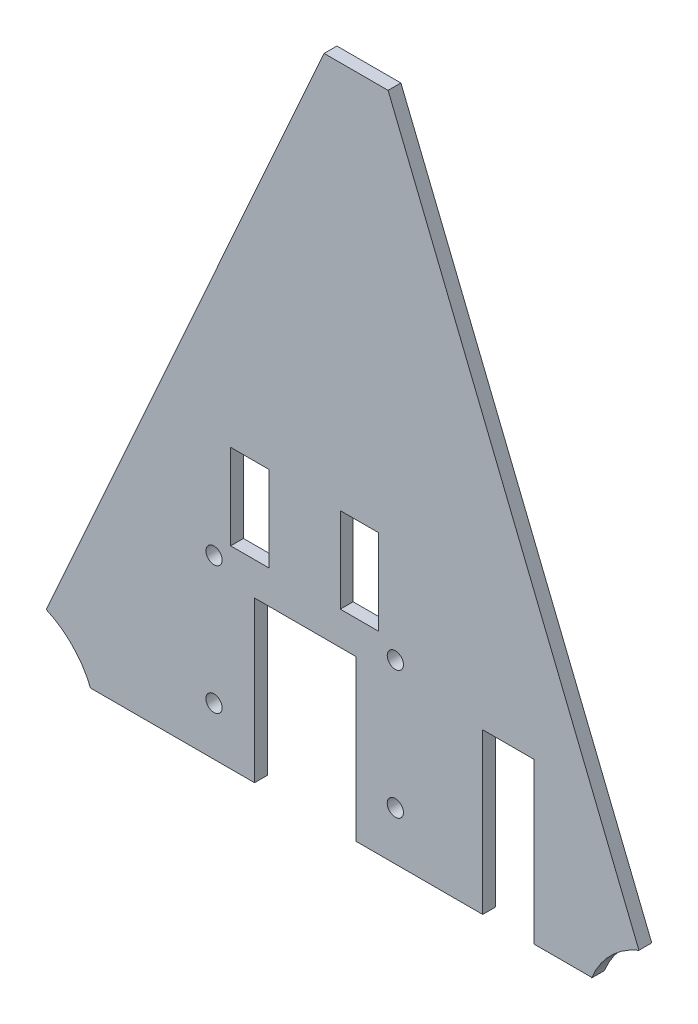
from build123d import *

# Parameters (mm, degrees)
BOSS_EXTRUDE1_DEPTH     = 7.62
SKETCH5_R               = 15.875
CUT_EXTRUDE2_DEPTH      = 50.8
SKETCH6_R               = 15.875
CUT_EXTRUDE3_DEPTH      = 50.8
CUT_EXTRUDE4_DEPTH      = 1
CUT_EXTRUDE4_DEPTH_BACK = 7.62
CUT_EXTRUDE6_REACH      = 9.62
SKETCH9_R               = 4.826
SKETCH10_W              = 30.48
SKETCH10_H              = 114.3
CUT_EXTRUDE12_DEPTH     = 25.4
CUT_EXTRUDE14_REACH     = 9.62
SKETCH14_R              = 50.8
CUT_EXTRUDE15_REACH     = 9.62
SKETCH15_R              = 50.8
CUT_EXTRUDE17_START     = -7.62
SKETCH18_W              = 300.609514784
SKETCH18_H              = 19.05
CUT_EXTRUDE17_DEPTH     = 7.62
CUT_EXTRUDE18_REACH     = 9.62
SKETCH19_R              = 4.826
CUT_EXTRUDE19_REACH     = 9.62
SKETCH20_W              = 22.86
SKETCH20_H              = 50.8
CUT_EXTRUDE20_REACH     = 9.62
SKETCH21_W              = 12.7
SKETCH21_H              = 95.25


with BuildPart() as part:
    # Sketch2 → Boss-Extrude1 (new body)
    with BuildSketch(Plane.XY):
        Polygon((-189.740054039, 245.383385713), (-375.90852523, -170.414614287), (16.77547477, -170.414614287), (-151.640054039, 245.383385713), align=None)
    extrude(amount=BOSS_EXTRUDE1_DEPTH)

    # Sketch5 → Cut-Extrude2 (cut)
    with BuildSketch(Plane(origin=(0, 0, 0), x_dir=(-1, 0, 0), z_dir=(0, 0, -1))):
        with Locations((375.90852523, -170.414614287)):
            Circle(SKETCH5_R)
    extrude(amount=-CUT_EXTRUDE2_DEPTH, mode=Mode.SUBTRACT)

    # Sketch6 → Cut-Extrude3 (cut)
    with BuildSketch(Plane(origin=(0, 0, 0), x_dir=(-1, 0, 0), z_dir=(0, 0, -1))):
        with Locations((-16.77547477, -170.414614287)):
            Circle(SKETCH6_R)
    extrude(amount=-CUT_EXTRUDE3_DEPTH, mode=Mode.SUBTRACT)

    # Sketch8 → Cut-Extrude4 (cut, two sides)
    with BuildSketch(Plane(origin=(0, 0, 0), x_dir=(-1, 0, 0), z_dir=(0, 0, -1))) as cut_extrude4_sk:
        Polygon((218.448947474, -1130.046710402), (218.448947474, -170.414614287), (218.448947474, -56.114614287), (183.523947474, -56.114614287), (183.523947474, -170.414614287), (183.523947474, -1130.046710402), (183.523947474, -3049.310902633), (218.448947474, -3049.310902633), align=None)
    extrude(amount=CUT_EXTRUDE4_DEPTH, mode=Mode.SUBTRACT)
    extrude(cut_extrude4_sk.sketch, amount=-CUT_EXTRUDE4_DEPTH_BACK, mode=Mode.SUBTRACT)

    # Sketch9 → Cut-Extrude6 (cut, up to next)
    with BuildSketch(Plane(origin=(0, 0, 0), x_dir=(-1, 0, 0), z_dir=(0, 0, -1)), mode=Mode.PRIVATE) as cut_extrude6_sk1:
        with Locations((147.328947474, -122.408614287)):
            Circle(SKETCH9_R)
    cut_extrude6_tool1 = extrude(cut_extrude6_sk1.sketch, amount=-CUT_EXTRUDE6_REACH, mode=Mode.PRIVATE) & part.part
    add(cut_extrude6_tool1.solids().sort_by_distance((-147.328947, -122.408614, 0))[0], mode=Mode.SUBTRACT)
    # Sketch9 → Cut-Extrude6 (cut, up to next)
    with BuildSketch(Plane(origin=(0, 0, 0), x_dir=(-1, 0, 0), z_dir=(0, 0, -1)), mode=Mode.PRIVATE) as cut_extrude6_sk2:
        with Locations((255.278947474, -122.408614287)):
            Circle(SKETCH9_R)
    cut_extrude6_tool2 = extrude(cut_extrude6_sk2.sketch, amount=-CUT_EXTRUDE6_REACH, mode=Mode.PRIVATE) & part.part
    add(cut_extrude6_tool2.solids().sort_by_distance((-255.278947, -122.408614, 0))[0], mode=Mode.SUBTRACT)

    # Sketch10 → Cut-Extrude12 (cut)
    with BuildSketch(Plane(origin=(0, 0, 0), x_dir=(-1, 0, 0), z_dir=(0, 0, -1))):
        with Locations((80.066257047, -113.264614287)):
            Rectangle(SKETCH10_W, SKETCH10_H)
    extrude(amount=-CUT_EXTRUDE12_DEPTH, mode=Mode.SUBTRACT)

    # Sketch14 → Cut-Extrude14 (cut, up to next)
    with BuildSketch(Plane(origin=(0, 0, 0), x_dir=(-1, 0, 0), z_dir=(0, 0, -1)), mode=Mode.PRIVATE) as cut_extrude14_sk1:
        with Locations((-16.77547477, -170.414614287)):
            Circle(SKETCH14_R)
    cut_extrude14_tool1 = extrude(cut_extrude14_sk1.sketch, amount=-CUT_EXTRUDE14_REACH, mode=Mode.PRIVATE) & part.part
    add(cut_extrude14_tool1.solids().sort_by_distance((16.775475, -170.414614, 0))[0], mode=Mode.SUBTRACT)

    # Sketch15 → Cut-Extrude15 (cut, up to next)
    with BuildSketch(Plane(origin=(0, 0, 0), x_dir=(-1, 0, 0), z_dir=(0, 0, -1)), mode=Mode.PRIVATE) as cut_extrude15_sk1:
        with Locations((375.90852523, -170.414614287)):
            Circle(SKETCH15_R)
    cut_extrude15_tool1 = extrude(cut_extrude15_sk1.sketch, amount=-CUT_EXTRUDE15_REACH, mode=Mode.PRIVATE) & part.part
    add(cut_extrude15_tool1.solids().sort_by_distance((-375.908525, -170.414614, 0))[0], mode=Mode.SUBTRACT)

    # Sketch18 → Cut-Extrude17 (cut)
    with BuildSketch(Plane(origin=(0, 0, 0), x_dir=(-1, 0, 0), z_dir=(0, 0, -1)).offset(CUT_EXTRUDE17_START)):
        with Locations((180.749872138, -160.889614287)):
            Rectangle(SKETCH18_W, SKETCH18_H)
    extrude(amount=CUT_EXTRUDE17_DEPTH, mode=Mode.SUBTRACT)

    # Sketch19 → Cut-Extrude18 (cut, up to next)
    with BuildSketch(Plane(origin=(0, 0, 0), x_dir=(-1, 0, 0), z_dir=(0, 0, -1)), mode=Mode.PRIVATE) as cut_extrude18_sk1:
        with Locations((255.278947474, -46.208614287)):
            Circle(SKETCH19_R)
    cut_extrude18_tool1 = extrude(cut_extrude18_sk1.sketch, amount=-CUT_EXTRUDE18_REACH, mode=Mode.PRIVATE) & part.part
    add(cut_extrude18_tool1.solids().sort_by_distance((-255.278947, -46.208614, 0))[0], mode=Mode.SUBTRACT)
    # Sketch19 → Cut-Extrude18 (cut, up to next)
    with BuildSketch(Plane(origin=(0, 0, 0), x_dir=(-1, 0, 0), z_dir=(0, 0, -1)), mode=Mode.PRIVATE) as cut_extrude18_sk2:
        with Locations((147.328947474, -46.208614287)):
            Circle(SKETCH19_R)
    cut_extrude18_tool2 = extrude(cut_extrude18_sk2.sketch, amount=-CUT_EXTRUDE18_REACH, mode=Mode.PRIVATE) & part.part
    add(cut_extrude18_tool2.solids().sort_by_distance((-147.328947, -46.208614, 0))[0], mode=Mode.SUBTRACT)

    # Sketch20 → Cut-Extrude19 (cut, up to next)
    with BuildSketch(Plane(origin=(0, 0, 0), x_dir=(-1, 0, 0), z_dir=(0, 0, -1)), mode=Mode.PRIVATE) as cut_extrude19_sk1:
        with Locations((168.664947474, -10.934247938)):
            Rectangle(SKETCH20_W, SKETCH20_H)
    cut_extrude19_tool1 = extrude(cut_extrude19_sk1.sketch, amount=-CUT_EXTRUDE19_REACH, mode=Mode.PRIVATE) & part.part
    add(cut_extrude19_tool1.solids().sort_by_distance((-168.664947, -10.934248, 0))[0], mode=Mode.SUBTRACT)
    # Sketch20 → Cut-Extrude19 (cut, up to next)
    with BuildSketch(Plane(origin=(0, 0, 0), x_dir=(-1, 0, 0), z_dir=(0, 0, -1)), mode=Mode.PRIVATE) as cut_extrude19_sk2:
        with Locations((233.942947474, -10.934247938)):
            Rectangle(SKETCH20_W, SKETCH20_H)
    cut_extrude19_tool2 = extrude(cut_extrude19_sk2.sketch, amount=-CUT_EXTRUDE19_REACH, mode=Mode.PRIVATE) & part.part
    add(cut_extrude19_tool2.solids().sort_by_distance((-233.942947, -10.934248, 0))[0], mode=Mode.SUBTRACT)

    # Sketch21 → Cut-Extrude20 (cut, up to next)
    with BuildSketch(Plane(origin=(0, 0, 0), x_dir=(-1, 0, 0), z_dir=(0, 0, -1)), mode=Mode.PRIVATE) as cut_extrude20_sk1:
        with Locations((224.798947474, -103.739614287)):
            Rectangle(SKETCH21_W, SKETCH21_H)
    cut_extrude20_tool1 = extrude(cut_extrude20_sk1.sketch, amount=-CUT_EXTRUDE20_REACH, mode=Mode.PRIVATE) & part.part
    add(cut_extrude20_tool1.solids().sort_by_distance((-224.798947, -103.739614, 0))[0], mode=Mode.SUBTRACT)
    # Sketch21 → Cut-Extrude20 (cut, up to next)
    with BuildSketch(Plane(origin=(0, 0, 0), x_dir=(-1, 0, 0), z_dir=(0, 0, -1)), mode=Mode.PRIVATE) as cut_extrude20_sk2:
        with Locations((177.173947474, -103.739614287)):
            Rectangle(SKETCH21_W, SKETCH21_H)
    cut_extrude20_tool2 = extrude(cut_extrude20_sk2.sketch, amount=-CUT_EXTRUDE20_REACH, mode=Mode.PRIVATE) & part.part
    add(cut_extrude20_tool2.solids().sort_by_distance((-177.173947, -103.739614, 0))[0], mode=Mode.SUBTRACT)


solid = part.part
